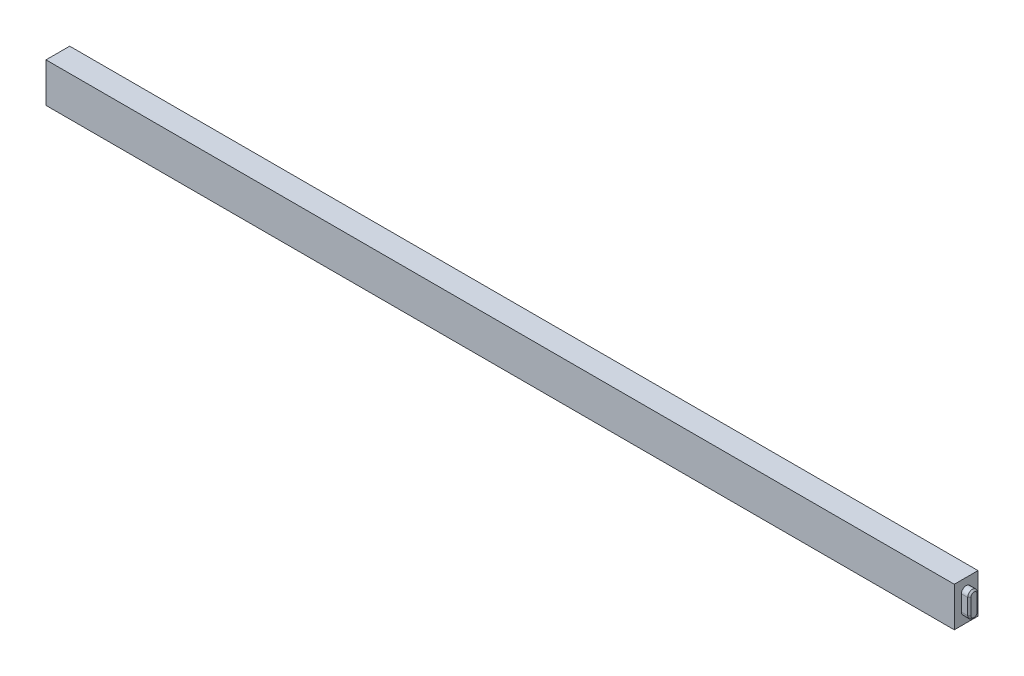
from build123d import *

# Parameters (mm, degrees)
ESQUISSE1_W        = 1150
ESQUISSE1_H        = 50
BOSS_EXTRU_1_DEPTH = 30
BOSS_EXTRU_2_DEPTH = 10
CHANFREIN1_SIZE    = 2
BOSS_EXTRU_3_DEPTH = 10
CHANFREIN2_SIZE    = 2


with BuildPart() as part:
    # Esquisse1 → Boss.-Extru.1 (new body)
    with BuildSketch(Plane.XY):
        Rectangle(ESQUISSE1_W, ESQUISSE1_H)
    extrude(amount=BOSS_EXTRU_1_DEPTH)

    # Esquisse2 → Boss.-Extru.2 (add)
    with BuildSketch(Plane(origin=(575, 0, 0), x_dir=(0, 0, -1), z_dir=(1, 0, 0))):
        with BuildLine():
            Line((-9, 10), (-9, -10))
            ThreePointArc((-9, -10), (-15, -16), (-21, -10))
            Line((-21, -10), (-21, 10))
            ThreePointArc((-21, 10), (-15, 16), (-9, 10))
        make_face()
    extrude(amount=BOSS_EXTRU_2_DEPTH)

    # Chanfrein1
    chanfrein1_edges = [part.edges().sort_by_distance(p)[0] for p in [
        (585, 16, 15),
        (585, 0, 21),
        (585, -16, 15),
        (585, 0, 9),
    ]]
    chamfer(chanfrein1_edges, length=CHANFREIN1_SIZE)

    # Esquisse3 → Boss.-Extru.3 (add)
    with BuildSketch(Plane.ZY.offset(575)):
        with BuildLine():
            Line((21, 10), (21, -10))
            ThreePointArc((21, -10), (15, -16), (9, -10))
            Line((9, -10), (9, 10))
            ThreePointArc((9, 10), (15, 16), (21, 10))
        make_face()
    extrude(amount=BOSS_EXTRU_3_DEPTH)

    # Chanfrein2
    chanfrein2_edges = [part.edges().sort_by_distance(p)[0] for p in [
        (-585, 0, 21),
        (-585, 16, 15),
        (-585, 0, 9),
        (-585, -16, 15),
    ]]
    chamfer(chanfrein2_edges, length=CHANFREIN2_SIZE)


solid = part.part
